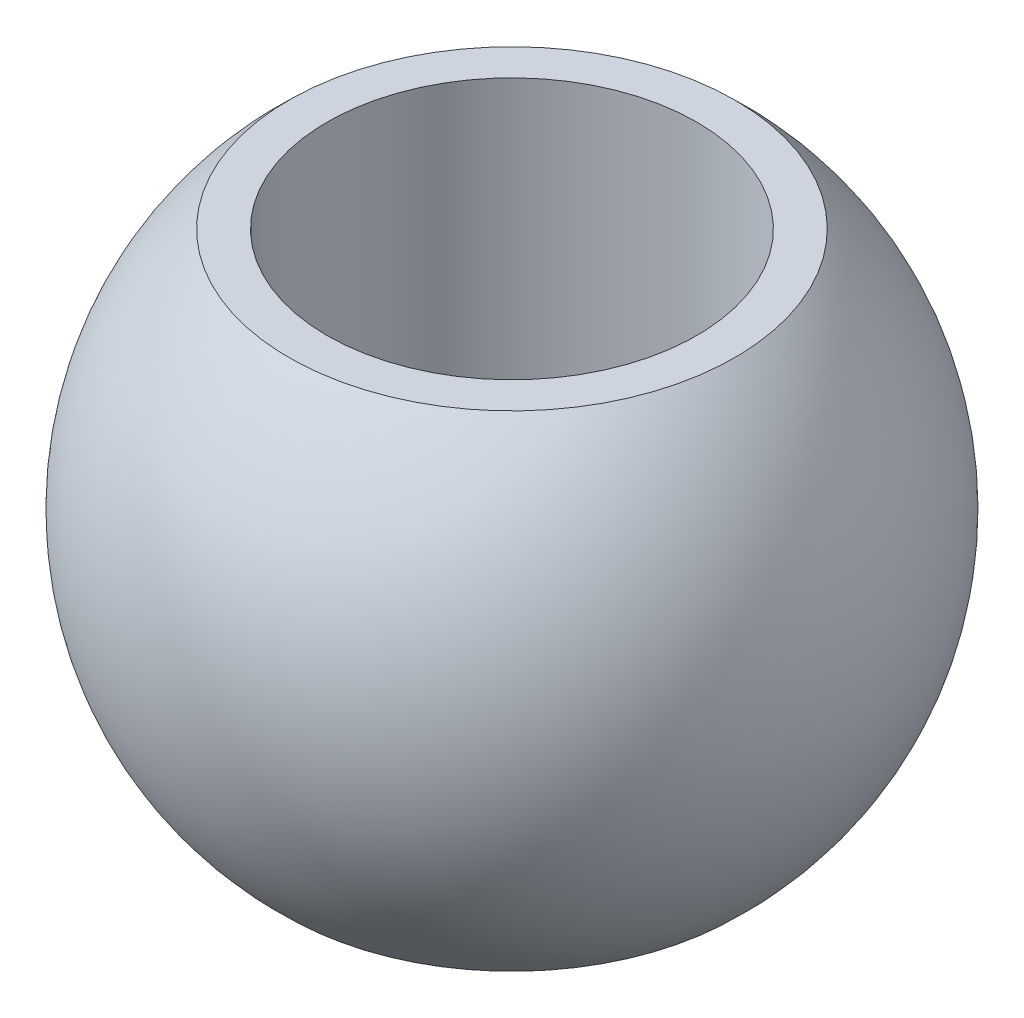
from build123d import *


with BuildPart() as part:
    # Szkic1 → Obrót1 (revolve)
    with BuildSketch(Plane.XY):
        with BuildLine():
            Line((8, -10.5), (8, 10.5))
            Line((8, 10.5), (9.648709758, 10.5))
            ThreePointArc((9.648709758, 10.5), (14.26, 0), (9.648709758, -10.5))
            Line((9.648709758, -10.5), (8, -10.5))
        make_face()
    revolve(axis=Axis((0, -11.1, 0), (0, 1, 0)))


solid = part.part
